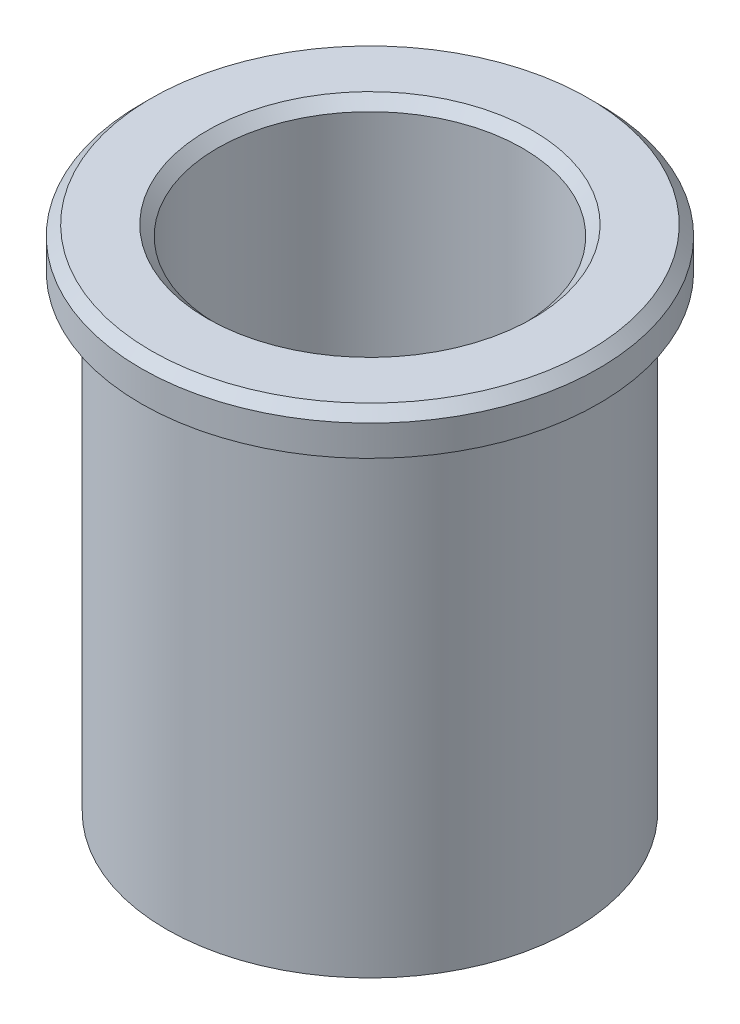
from build123d import *


with BuildPart() as part:
    # Esquisse1 → Révolution1 (revolve)
    with BuildSketch(Plane.XY):
        Polygon((16, 0), (21.5, 0), (22.5, -1), (22.5, -4), (20, -4), (20, -50), (16, -50), (15, -49), (15, -1), align=None)
    revolve(axis=Axis((0, 22.616438356, 0), (0, -1, 0)))


solid = part.part
